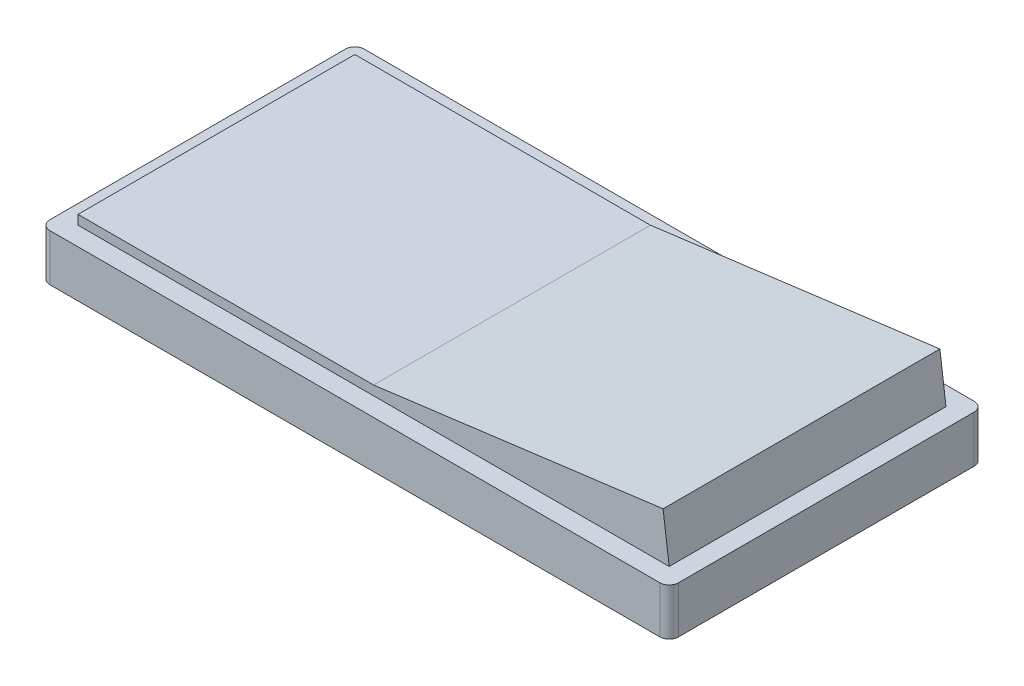
from build123d import *

# Parameters (mm, degrees)
SKETCH1_W               = 67
SKETCH1_H               = 33.5
BOSS_EXTRUDE1_DEPTH     = 5
FILLET1_R               = 1
SKETCH2_W               = 63
SKETCH2_H               = 29.5
BOSS_EXTRUDE2_DEPTH     = 5
CUT_EXTRUDE1_DEPTH      = 3
CUT_EXTRUDE1_DEPTH_BACK = 32.5


with BuildPart() as part:
    # Sketch1 → Boss-Extrude1 (new body)
    with BuildSketch(Plane(origin=(0, 0, 0), x_dir=(1, 0, 0), z_dir=(0, 1, 0))):
        Rectangle(SKETCH1_W, SKETCH1_H)
    extrude(amount=BOSS_EXTRUDE1_DEPTH)

    # Fillet1
    fillet1_edges = [part.edges().sort_by_distance(p)[0] for p in [
        (33.5, 2.5, 16.75),
        (-33.5, 2.5, 16.75),
        (-33.5, 2.5, -16.75),
        (33.5, 2.5, -16.75),
    ]]
    fillet(fillet1_edges, radius=FILLET1_R)

    # Sketch2 → Boss-Extrude2 (add)
    with BuildSketch(Plane(origin=(0, 5, 0), x_dir=(1, 0, 0), z_dir=(0, 1, 0))):
        Rectangle(SKETCH2_W, SKETCH2_H)
    extrude(amount=BOSS_EXTRUDE2_DEPTH)

    # Sketch3 → Cut-Extrude1 (cut, two sides)
    with BuildSketch(Plane.XY.offset(14.75)) as cut_extrude1_sk:
        Polygon((-31.5, 6), (0, 6), (30.851738311, 10), (-31.5, 10), align=None)
        Polygon((31.5, 10), (30.851738311, 10), (31.5, 5), align=None)
    extrude(amount=CUT_EXTRUDE1_DEPTH, mode=Mode.SUBTRACT)
    extrude(cut_extrude1_sk.sketch, amount=-CUT_EXTRUDE1_DEPTH_BACK, mode=Mode.SUBTRACT)


solid = part.part
